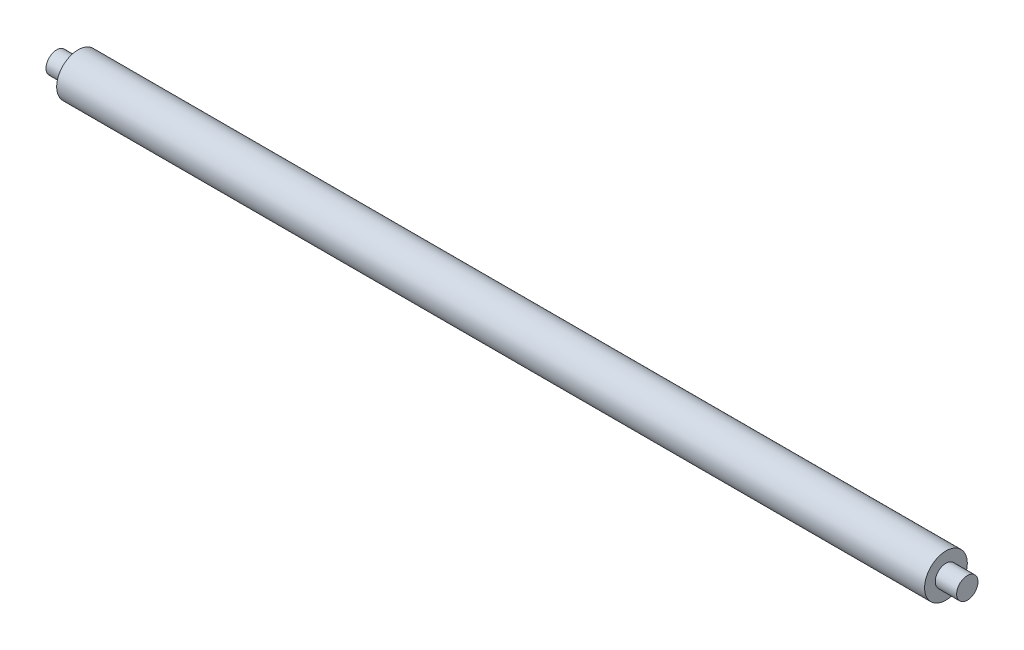
from build123d import *

# Parameters (mm, degrees)
CROQUIS1_R              = 5
SALIENTE_EXTRUIR1_DEPTH = 101.5
CROQUIS2_R              = 2.5
SALIENTE_EXTRUIR2_DEPTH = 106.5


with BuildPart() as part:
    # Croquis1 → Saliente-Extruir1 (new body, symmetric)
    with BuildSketch(Plane(origin=(0, 0, 0), x_dir=(0, 0, -1), z_dir=(1, 0, 0))):
        Circle(CROQUIS1_R)
    extrude(amount=SALIENTE_EXTRUIR1_DEPTH, both=True)

    # Croquis2 → Saliente-Extruir2 (add, symmetric)
    with BuildSketch(Plane(origin=(0, 0, 0), x_dir=(0, 0, -1), z_dir=(1, 0, 0))):
        Circle(CROQUIS2_R)
    extrude(amount=SALIENTE_EXTRUIR2_DEPTH, both=True)


solid = part.part
